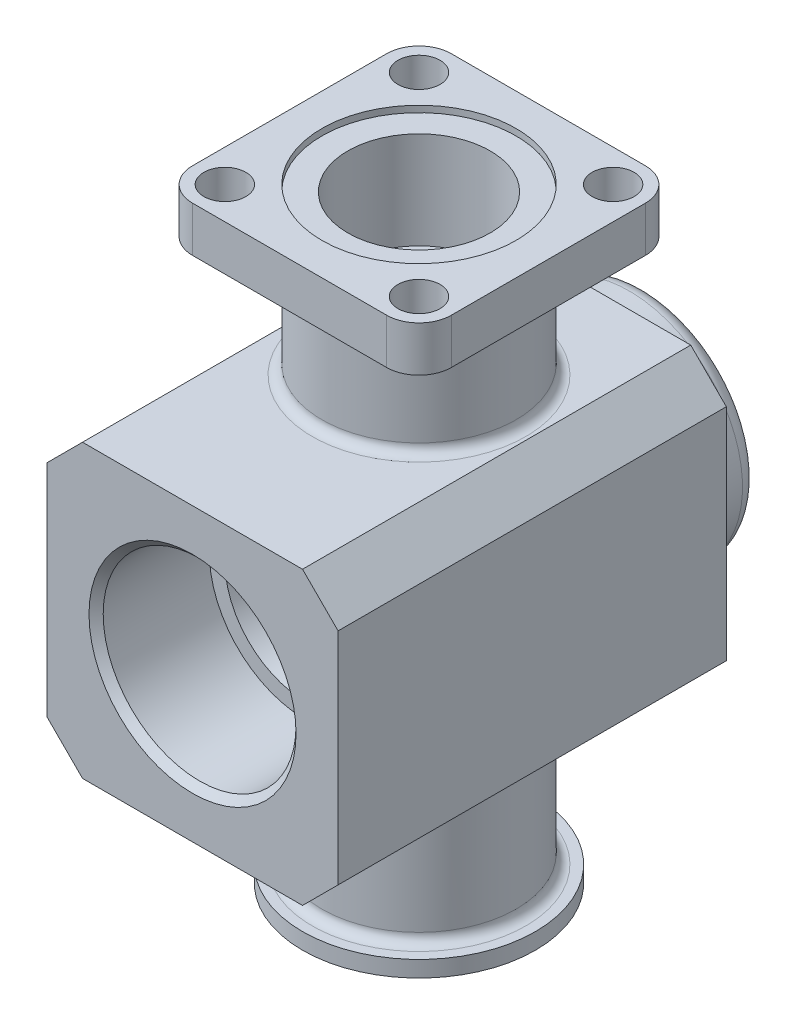
from build123d import *

# Parameters (mm, degrees)
SKETCH_1_W          = 90
SKETCH_1_H          = 90
EXTRUDE_1_DEPTH     = 120
SKETCH_9_R          = 35
EXTRUDE_6_DEPTH     = 20
SKETCH_2_R          = 30
EXTRUDE_2_DEPTH     = 51
SKETCH_3_W          = 80
SKETCH_3_H          = 80
EXTRUDE_3_DEPTH     = 14
SKETCH_4_R          = 30
EXTRUDE_4_DEPTH     = 46
SKETCH_5_R          = 36
EXTRUDE_5_DEPTH     = 5
SKETCH_6_R          = 15
CUT_EXTRUDE_1_DEPTH = 188
SKETCH_7_R          = 22
CUT_EXTRUDE_2_DEPTH = 32
SKETCH_8_R          = 22.352
CUT_EXTRUDE_3_DEPTH = 36
FILLET_1_R          = 10
SKETCH_10_R         = 6.5
CUT_EXTRUDE_4_DEPTH = 14
CHAMFER_1_SIZE      = 11
FILLET_2_R          = 5
SKETCH_11_R         = 29.805
CUT_EXTRUDE_5_DEPTH = 35
CHAMFER_2_SIZE      = 2.195
SKETCH_14_R         = 30
CUT_EXTRUDE_6_DEPTH = 2
FILLET_3_R          = 3
CHAMFER_4_SIZE      = 1.648


with BuildPart() as part:
    # Эскиз1 → Бобышка-Вытянуть1 (new body)
    with BuildSketch(Plane.XY):
        Rectangle(SKETCH_1_W, SKETCH_1_H)
    extrude(amount=EXTRUDE_1_DEPTH)

    # Эскиз9 → Бобышка-Вытянуть6 (add)
    with BuildSketch(Plane(origin=(0, 0, 0), x_dir=(-1, 0, 0), z_dir=(0, 0, -1))):
        Circle(SKETCH_9_R)
    extrude(amount=EXTRUDE_6_DEPTH)

    # Эскиз2 → Бобышка-Вытянуть2 (add)
    with BuildSketch(Plane(origin=(0, 45, 0), x_dir=(1, 0, 0), z_dir=(0, 1, 0))):
        with Locations((0, -50)):
            Circle(SKETCH_2_R)
    extrude(amount=EXTRUDE_2_DEPTH)

    # Эскиз3 → Бобышка-Вытянуть3 (add)
    with BuildSketch(Plane(origin=(0, 96, 0), x_dir=(1, 0, 0), z_dir=(0, 1, 0))):
        with Locations((0, -50)):
            Rectangle(SKETCH_3_W, SKETCH_3_H)
    extrude(amount=-EXTRUDE_3_DEPTH)

    # Эскиз4 → Бобышка-Вытянуть4 (add)
    with BuildSketch(Plane.XZ.offset(45)):
        with Locations((0, 50)):
            Circle(SKETCH_4_R)
    extrude(amount=EXTRUDE_4_DEPTH)

    # Эскиз5 → Бобышка-Вытянуть5 (add)
    with BuildSketch(Plane.XZ.offset(91)):
        with Locations((0, 50)):
            Circle(SKETCH_5_R)
    extrude(amount=-EXTRUDE_5_DEPTH)

    # Эскиз6 → Вырез-Вытянуть1 (cut, through all)
    with BuildSketch(Plane(origin=(0, -91, 0), x_dir=(-1, 0, 0), z_dir=(0, -1, 0))):
        with Locations((0, -50)):
            Circle(SKETCH_6_R)
    extrude(amount=-CUT_EXTRUDE_1_DEPTH, mode=Mode.SUBTRACT)

    # Эскиз7 → Вырез-Вытянуть2 (cut)
    with BuildSketch(Plane(origin=(0, 96, 0), x_dir=(1, 0, 0), z_dir=(0, 1, 0))):
        with Locations((0, -50)):
            Circle(SKETCH_7_R)
    extrude(amount=-CUT_EXTRUDE_2_DEPTH, mode=Mode.SUBTRACT)

    # Эскиз8 → Вырез-Вытянуть3 (cut)
    with BuildSketch(Plane.XZ.offset(91)):
        with Locations((0, 50)):
            Circle(SKETCH_8_R)
    extrude(amount=-CUT_EXTRUDE_3_DEPTH, mode=Mode.SUBTRACT)

    # Скругление1
    fillet_1_edges = [part.edges().sort_by_distance(p)[0] for p in [
        (40, 89, 10),
        (40, 89, 90),
        (-40, 89, 90),
        (-40, 89, 10),
    ]]
    fillet(fillet_1_edges, radius=FILLET_1_R)

    # Эскиз10 → Вырез-Вытянуть4 (cut)
    with BuildSketch(Plane(origin=(0, 96, 0), x_dir=(1, 0, 0), z_dir=(0, 1, 0))):
        with Locations((-30, -20)):
            Circle(SKETCH_10_R)
        with Locations((30, -80)):
            Circle(SKETCH_10_R)
        with Locations((30, -20)):
            Circle(SKETCH_10_R)
        with Locations((-30, -80)):
            Circle(SKETCH_10_R)
    extrude(amount=-CUT_EXTRUDE_4_DEPTH, mode=Mode.SUBTRACT)

    # Фаска1
    chamfer_1_edges = [part.edges().sort_by_distance(p)[0] for p in [
        (45, -45, 60),
        (-45, -45, 60),
        (-45, 45, 60),
        (45, 45, 60),
    ]]
    chamfer(chamfer_1_edges, length=CHAMFER_1_SIZE)

    # Скругление2
    fillet_2_edges = [part.edges().sort_by_distance(p)[0] for p in [
        (35, 0, 0),
        (35, 0, -20),
    ]]
    fillet(fillet_2_edges, radius=FILLET_2_R)

    # Эскиз11 → Вырез-Вытянуть5 (cut)
    with BuildSketch(Plane.XY.offset(120)):
        Circle(SKETCH_11_R)
    extrude(amount=-CUT_EXTRUDE_5_DEPTH, mode=Mode.SUBTRACT)

    # Эскиз13 → Вырез-Повернуть1 (revolve, cut)
    with BuildSketch(Plane(origin=(0, 0, 0), x_dir=(0, 0, -1), z_dir=(1, 0, 0))):
        Polygon((-85, 25), (5, 12.351324877), (5, 0), (-85, 0), align=None)
    revolve(axis=Axis((0, 0, 0), (0, 0, 1)), mode=Mode.SUBTRACT)

    # Фаска2
    chamfer_2_edges = [part.edges().sort_by_distance(p)[0] for p in [
        (-29.805, 0, 120),
    ]]
    chamfer(chamfer_2_edges, length=CHAMFER_2_SIZE)

    # Эскиз14 → Вырез-Вытянуть6 (cut)
    with BuildSketch(Plane(origin=(0, 96, 0), x_dir=(1, 0, 0), z_dir=(0, 1, 0))):
        with Locations((0, -50)):
            Circle(SKETCH_14_R)
    extrude(amount=-CUT_EXTRUDE_6_DEPTH, mode=Mode.SUBTRACT)

    # Скругление3
    fillet_3_edges = [part.edges().sort_by_distance(p)[0] for p in [
        (-30, 45, 50),
        (-30, 82, 50),
        (-30, -45, 50),
        (-30, -86, 50),
    ]]
    fillet(fillet_3_edges, radius=FILLET_3_R)

    # Фаска4
    chamfer_4_edges = [part.edges().sort_by_distance(p)[0] for p in [
        (-22.352, -91, 50),
    ]]
    chamfer(chamfer_4_edges, length=CHAMFER_4_SIZE)


solid = part.part
